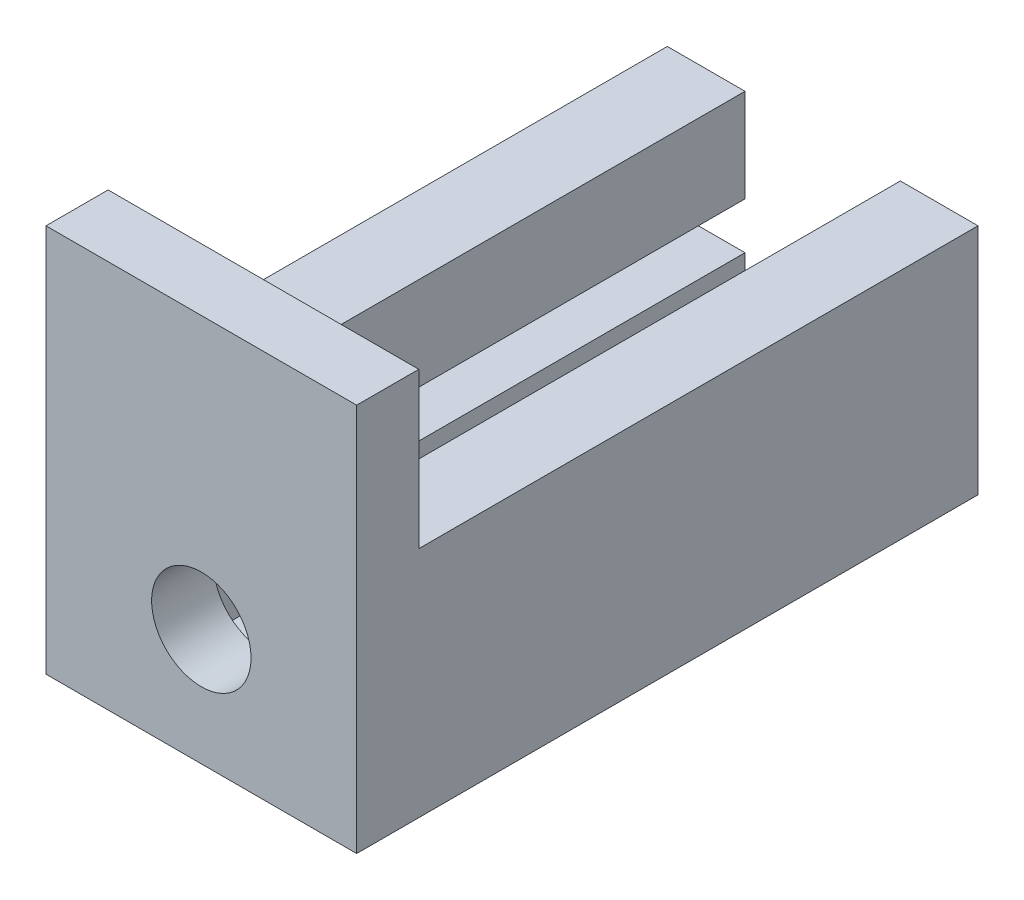
from build123d import *

# Parameters (mm, degrees)
BOSS_EXTRU_1_DEPTH      = 36
ESQUISSE2_W             = 20
ESQUISSE2_H             = 15
BOSS_EXTRU_2_DEPTH      = 4
ESQUISSE3_R             = 3.2
ENL_V_MAT_EXTRU_1_DEPTH = 4
ESQUISSE4_W             = 20
ESQUISSE4_H             = 4
BOSS_EXTRU_3_DEPTH      = 10


with BuildPart() as part:
    # Esquisse1 → Boss.-Extru.1 (new body)
    with BuildSketch(Plane.XY):
        Polygon((0, 0), (-5, 0), (-5, 15), (0, 15), (0, 9), (-3, 9), (-3, 6), (0, 6), (0, 2), (10, 2), (10, 6), (13, 6), (13, 9), (10, 9), (10, 15), (15, 15), (15, 0), (10, 0), align=None)
    extrude(amount=BOSS_EXTRU_1_DEPTH)

    # Esquisse2 → Boss.-Extru.2 (add)
    with BuildSketch(Plane.XY.offset(36)):
        with Locations((5, 7.5)):
            Rectangle(ESQUISSE2_W, ESQUISSE2_H)
    extrude(amount=BOSS_EXTRU_2_DEPTH)

    # Esquisse3 → Enlèv. mat.-Extru.1 (cut)
    with BuildSketch(Plane.XY.offset(40)):
        with Locations((5, 7.5)):
            Circle(ESQUISSE3_R)
    extrude(amount=-ENL_V_MAT_EXTRU_1_DEPTH, mode=Mode.SUBTRACT)

    # Esquisse4 → Boss.-Extru.3 (add)
    with BuildSketch(Plane(origin=(0, 15, 0), x_dir=(1, 0, 0), z_dir=(0, 1, 0))):
        with Locations((5, -38)):
            Rectangle(ESQUISSE4_W, ESQUISSE4_H)
    extrude(amount=BOSS_EXTRU_3_DEPTH)


solid = part.part
